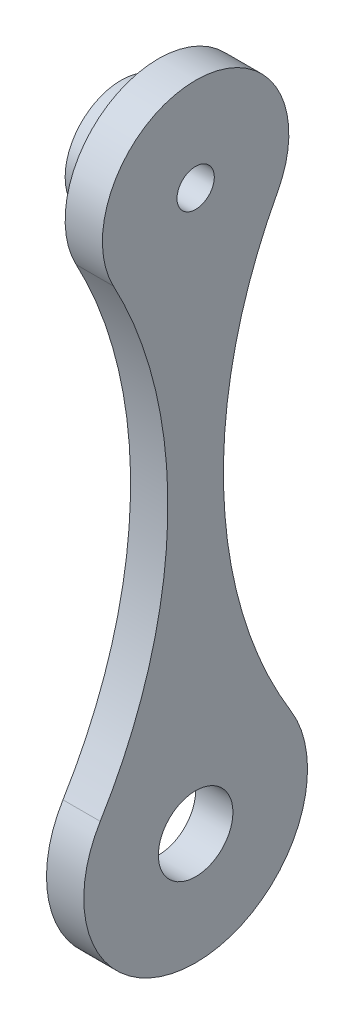
from build123d import *

# Parameters (mm, degrees)
SKETCH1_R           = 10
BOSS_EXTRUDE1_DEPTH = 10
SKETCH3_R           = 15
BOSS_EXTRUDE3_DEPTH = 10
SKETCH4_R           = 5
CUT_EXTRUDE1_DEPTH  = 20


with BuildPart() as part:
    # Sketch1 → Boss-Extrude1 (new body)
    with BuildSketch(Plane(origin=(0, 0, 0), x_dir=(0, 0, -1), z_dir=(1, 0, 0))):
        with BuildLine():
            ThreePointArc((22.040471077, -91.799052281), (0, -55), (-22.040471077, -91.799052281))
            ThreePointArc((-22.040471077, -91.799052281), (-7.5, -153.539335996), (-25.58571686, -214.33567452))
            ThreePointArc((-25.58571686, -214.33567452), (0, -260), (25.58571686, -214.33567452))
            ThreePointArc((25.58571686, -214.33567452), (7.5, -153.539335996), (22.040471077, -91.799052281))
        make_face()
        with Locations((0, -230)):
            Circle(SKETCH1_R, mode=Mode.SUBTRACT)
    extrude(amount=BOSS_EXTRUDE1_DEPTH)

    # Sketch3 → Boss-Extrude3 (add)
    with BuildSketch(Plane.ZY):
        with Locations((0, -80)):
            Circle(SKETCH3_R)
    extrude(amount=BOSS_EXTRUDE3_DEPTH)

    # Sketch4 → Cut-Extrude1 (cut)
    with BuildSketch(Plane.ZY.offset(10)):
        with Locations((0, -80)):
            Circle(SKETCH4_R)
    extrude(amount=-CUT_EXTRUDE1_DEPTH, mode=Mode.SUBTRACT)


solid = part.part
